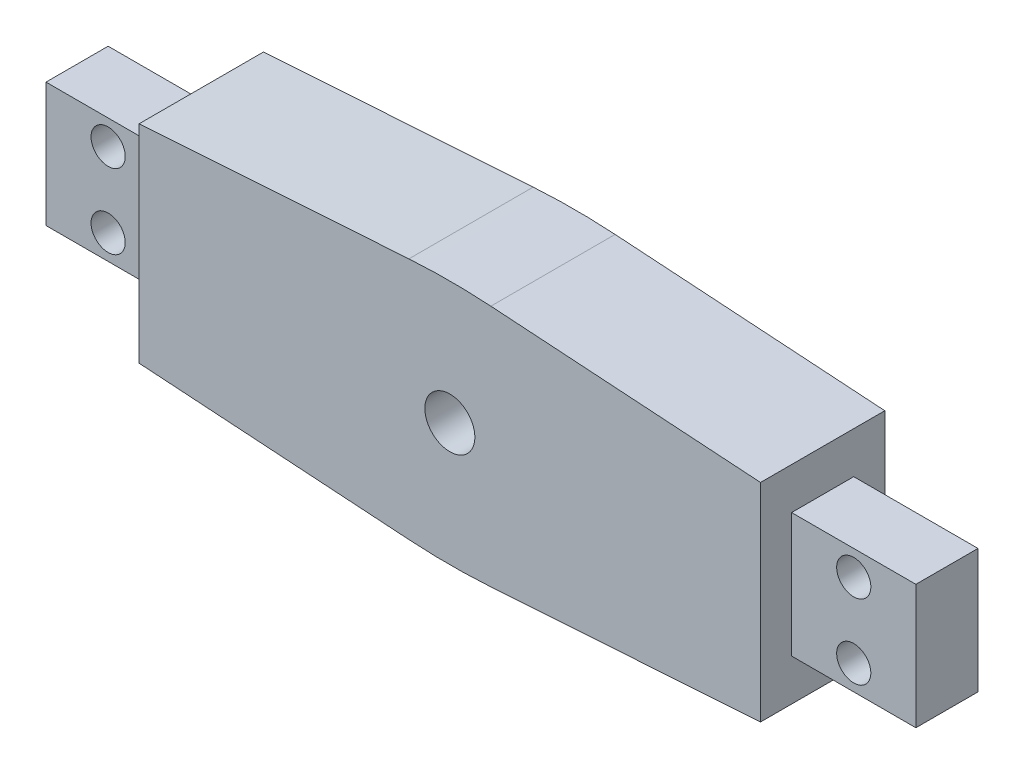
from build123d import *

# Parameters (mm, degrees)
SKETCH1_R           = 4.025
BOSS_EXTRUDE1_DEPTH = 20
FILLET1_R           = 100
SKETCH2_W           = 10
SKETCH2_H           = 20
BOSS_EXTRUDE2_DEPTH = 20
SKETCH3_R           = 2.75
CUT_EXTRUDE1_DEPTH  = 16


with BuildPart() as part:
    # Sketch1 → Boss-Extrude1 (new body)
    with BuildSketch(Plane.XY):
        Polygon((50, 16.695671227), (50, -16.695671227), (0, -20), (-50, -16.695671227), (-50, 16.695671227), (0, 20), align=None)
        Circle(SKETCH1_R, mode=Mode.SUBTRACT)
    extrude(amount=BOSS_EXTRUDE1_DEPTH)

    # Fillet1
    fillet1_edges = [part.edges().sort_by_distance(p)[0] for p in [
        (0, -20, 10),
        (0, 20, 10),
    ]]
    fillet(fillet1_edges, radius=FILLET1_R)

    # Sketch2 → Boss-Extrude2 (add)
    with BuildSketch(Plane(origin=(50, 0, 0), x_dir=(0, 0, -1), z_dir=(1, 0, 0))):
        with Locations((-10, 0)):
            Rectangle(SKETCH2_W, SKETCH2_H)
    boss_extrude2 = extrude(amount=BOSS_EXTRUDE2_DEPTH)

    # Mirror1: Boss-Extrude2 across plane
    add(boss_extrude2.mirror(Plane(origin=(0, 0, 0), x_dir=(0, 0, 1), z_dir=(1, 0, 0))))

    # Sketch3 → Cut-Extrude1 (cut, through all)
    with BuildSketch(Plane(origin=(0, 0, 5), x_dir=(-1, 0, 0), z_dir=(0, 0, -1))):
        with Locations((60, -6)):
            Circle(SKETCH3_R)
        with Locations((60, 6)):
            Circle(SKETCH3_R)
        with Locations((-60, -6)):
            Circle(SKETCH3_R)
        with Locations((-60, 6)):
            Circle(SKETCH3_R)
    extrude(amount=-CUT_EXTRUDE1_DEPTH, mode=Mode.SUBTRACT)


solid = part.part
